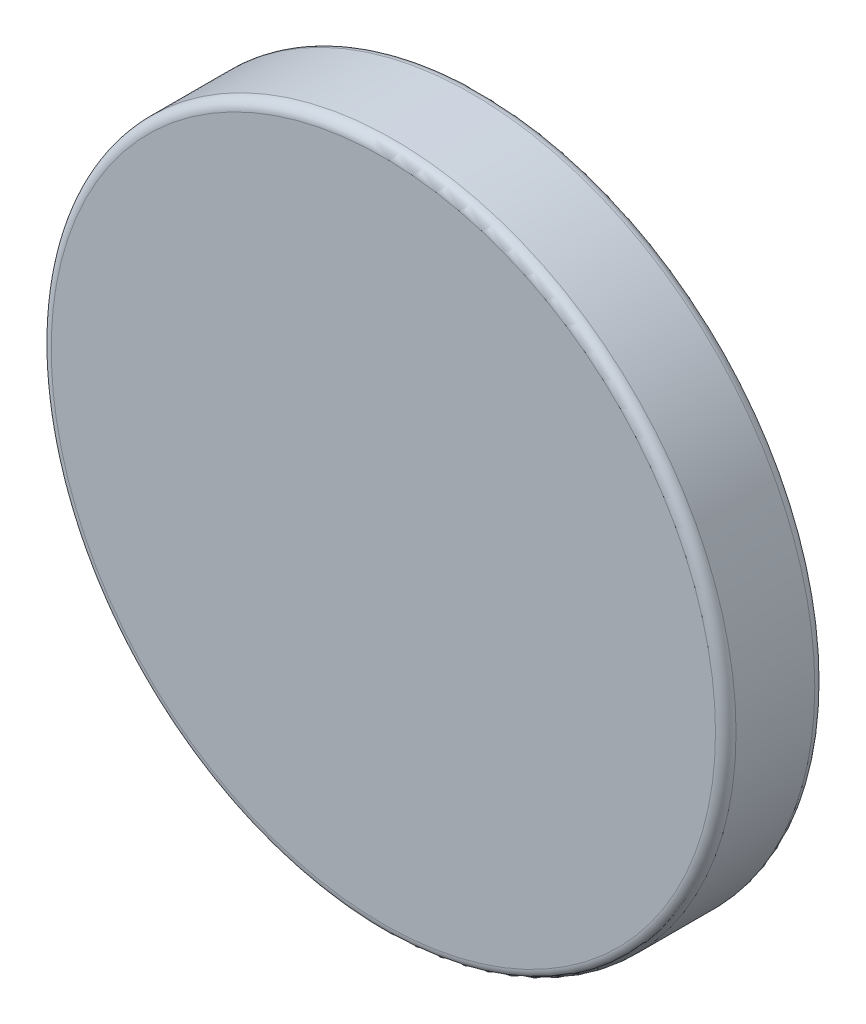
from build123d import *

# Parameters (mm, degrees)
SKICA1_R                = 5
P_IDAT_VYSUNUT_M1_DEPTH = 1.45
ZAOBLIT1_R              = 0.15


with BuildPart() as part:
    # Skica1 → Přidat vysunutím1 (new body)
    with BuildSketch(Plane.XY):
        Circle(SKICA1_R)
    extrude(amount=P_IDAT_VYSUNUT_M1_DEPTH)

    # Zaoblit1
    zaoblit1_edges = [part.edges().sort_by_distance(p)[0] for p in [
        (-5, 0, 0),
        (-5, 0, 1.45),
    ]]
    fillet(zaoblit1_edges, radius=ZAOBLIT1_R)


solid = part.part
